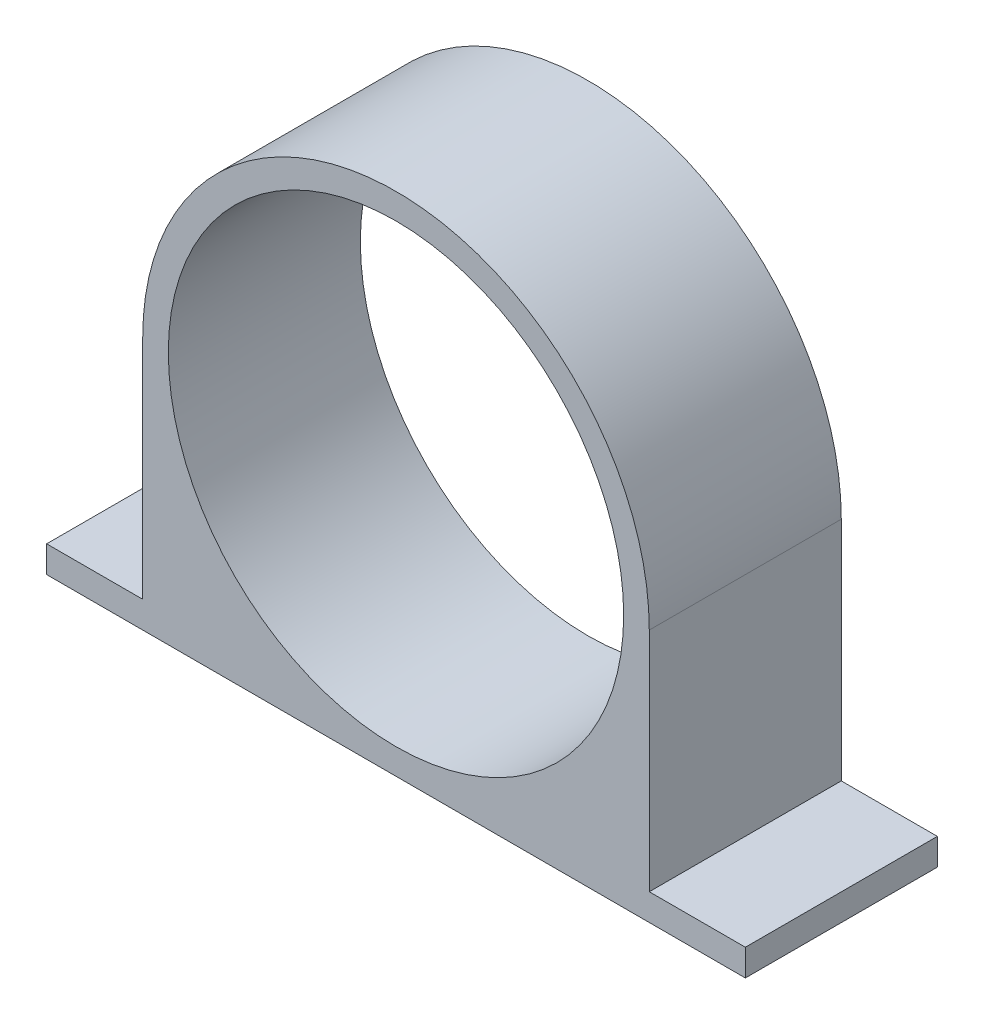
from build123d import *

# Parameters (mm, degrees)
SKETCH1_R           = 33.375
SKETCH1_R_2         = 30.007470458
BOSS_EXTRUDE1_DEPTH = 25.3
BASE_W              = 92.07
BASE_H              = 3.511684016
BOSS_EXTRUDE3_DEPTH = 25.3
SKETCH7_W           = 66.75
SKETCH7_H           = 25.3
BOSS_EXTRUDE4_DEPTH = 33.3
SKETCH2_R           = 30
CUT_EXTRUDE4_DEPTH  = 33.3


with BuildPart() as part:
    # Sketch1 → Boss-Extrude1 (new body)
    with BuildSketch(Plane.XY):
        Circle(SKETCH1_R)
        Circle(SKETCH1_R_2, mode=Mode.SUBTRACT)
        Circle(SKETCH1_R_2)
    extrude(amount=BOSS_EXTRUDE1_DEPTH)

    # Base → Boss-Extrude3 (add)
    with BuildSketch(Plane.XY):
        with Locations((0, -31.619157992)):
            Rectangle(BASE_W, BASE_H)
    extrude(amount=BOSS_EXTRUDE3_DEPTH)

    # Sketch7 → Boss-Extrude4 (add)
    with BuildSketch(Plane(origin=(0, 0, 0), x_dir=(1, 0, 0), z_dir=(0, 1, 0))):
        with Locations((0, -12.65)):
            Rectangle(SKETCH7_W, SKETCH7_H)
    extrude(amount=-BOSS_EXTRUDE4_DEPTH)

    # Sketch2 → Cut-Extrude4 (cut)
    with BuildSketch(Plane(origin=(0, 0, 0), x_dir=(-1, 0, 0), z_dir=(0, 0, -1))):
        Circle(SKETCH2_R)
    extrude(amount=-CUT_EXTRUDE4_DEPTH, mode=Mode.SUBTRACT)


solid = part.part
